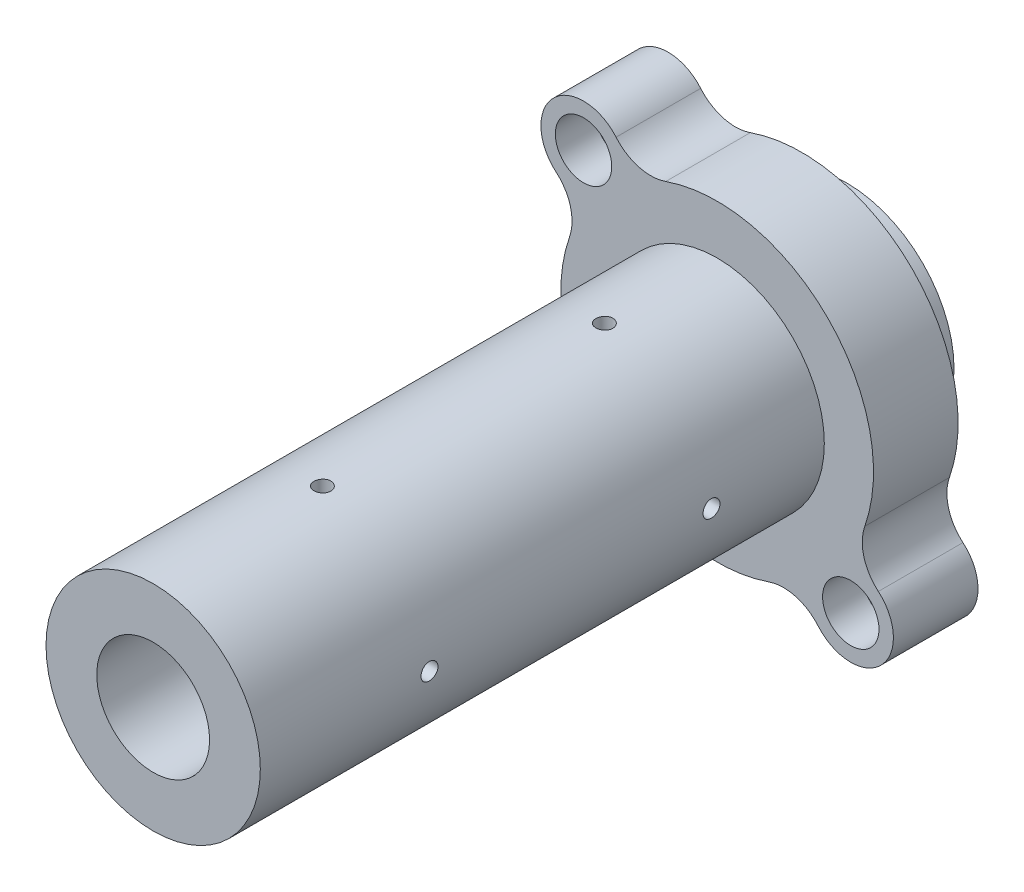
from build123d import *

# Parameters (mm, degrees)
ESQUISSE1_R                  = 2.65
BOSS_EXTRU_1_DEPTH           = 15
ESQUISSE9_R                  = 19
BOSS_EXTRU_4_DEPTH           = 100
BOSS_EXTRU_4_DEPTH_BACK      = 23
ESQUISSE12_R                 = 10
ENL_V_MAT_EXTRU_2_DEPTH      = 124
ESQUISSE13_R                 = 5
ENL_V_MAT_EXTRU_3_DEPTH      = 7
ESQUISSE14_R                 = 1.5
ENL_V_MAT_EXTRU_4_DEPTH      = 32.248101798
ENL_V_MAT_EXTRU_4_DEPTH_BACK = 32.248101798
ESQUISSE15_R                 = 1.5
ENL_V_MAT_EXTRU_5_DEPTH      = 32.248101798
ENL_V_MAT_EXTRU_5_DEPTH_BACK = 32.248101798


with BuildPart() as part:
    # Esquisse1 → Boss.-Extru.1 (new body)
    with BuildSketch(Plane.XY.offset(838.2)):
        with BuildLine():
            ThreePointArc((-9.11861011, 26.177363431), (-13.892343586, 26.012514183), (-17.921893066, 28.577360682))
            ThreePointArc((-17.921893066, 28.577360682), (-29.033821851, 29.033821851), (-28.577360682, 17.921893066))
            ThreePointArc((-28.577360682, 17.921893066), (-26.012514183, 13.892343586), (-26.177363431, 9.11861011))
            ThreePointArc((-26.177363431, 9.11861011), (-19.60106383, -19.60106383), (9.11861011, -26.177363431))
            ThreePointArc((9.11861011, -26.177363431), (13.892343586, -26.012514183), (17.921893066, -28.577360682))
            ThreePointArc((17.921893066, -28.577360682), (29.033821851, -29.033821851), (28.577360682, -17.921893066))
            ThreePointArc((28.577360682, -17.921893066), (26.012514183, -13.892343586), (26.177363431, -9.11861011))
            ThreePointArc((26.177363431, -9.11861011), (19.60106383, 19.60106383), (-9.11861011, 26.177363431))
        make_face()
        with Locations((23.68807717, -23.68807717)):
            Circle(ESQUISSE1_R, mode=Mode.SUBTRACT)
        with Locations((-23.68807717, 23.68807717)):
            Circle(ESQUISSE1_R, mode=Mode.SUBTRACT)
    extrude(amount=-BOSS_EXTRU_1_DEPTH)

    # Esquisse9 → Boss.-Extru.4 (add, two sides)
    with BuildSketch(Plane.XY.offset(838.2)) as boss_extru_4_sk:
        Circle(ESQUISSE9_R)
    extrude(amount=BOSS_EXTRU_4_DEPTH)
    extrude(boss_extru_4_sk.sketch, amount=-BOSS_EXTRU_4_DEPTH_BACK)

    # Esquisse12 → Enlèv. mat.-Extru.2 (cut, through all)
    with BuildSketch(Plane.XY.offset(938.2)):
        Circle(ESQUISSE12_R)
    extrude(amount=-ENL_V_MAT_EXTRU_2_DEPTH, mode=Mode.SUBTRACT)

    # Esquisse13 → Enlèv. mat.-Extru.3 (cut)
    with BuildSketch(Plane.XY.offset(838.2)):
        with Locations((-23.68807717, 23.68807717)):
            Circle(ESQUISSE13_R)
        with Locations((23.68807717, -23.68807717)):
            Circle(ESQUISSE13_R)
    extrude(amount=-ENL_V_MAT_EXTRU_3_DEPTH, mode=Mode.SUBTRACT)

    # Esquisse14 → Enlèv. mat.-Extru.4 (cut, two sides)
    with BuildSketch(Plane(origin=(0, 0, 0), x_dir=(1, 0, 0), z_dir=(0, 1, 0))) as enl_v_mat_extru_4_sk:
        with Locations((0, -858.2)):
            Circle(ESQUISSE14_R)
        with Locations((0, -908.2)):
            Circle(ESQUISSE14_R)
    extrude(amount=ENL_V_MAT_EXTRU_4_DEPTH, mode=Mode.SUBTRACT)
    extrude(enl_v_mat_extru_4_sk.sketch, amount=-ENL_V_MAT_EXTRU_4_DEPTH_BACK, mode=Mode.SUBTRACT)

    # Esquisse15 → Enlèv. mat.-Extru.5 (cut, two sides)
    with BuildSketch(Plane(origin=(0, 0, 0), x_dir=(0, 0, -1), z_dir=(1, 0, 0))) as enl_v_mat_extru_5_sk:
        with Locations((-858.2, 0)):
            Circle(ESQUISSE15_R)
        with Locations((-908.2, 0)):
            Circle(ESQUISSE15_R)
    extrude(amount=ENL_V_MAT_EXTRU_5_DEPTH, mode=Mode.SUBTRACT)
    extrude(enl_v_mat_extru_5_sk.sketch, amount=-ENL_V_MAT_EXTRU_5_DEPTH_BACK, mode=Mode.SUBTRACT)


solid = part.part
